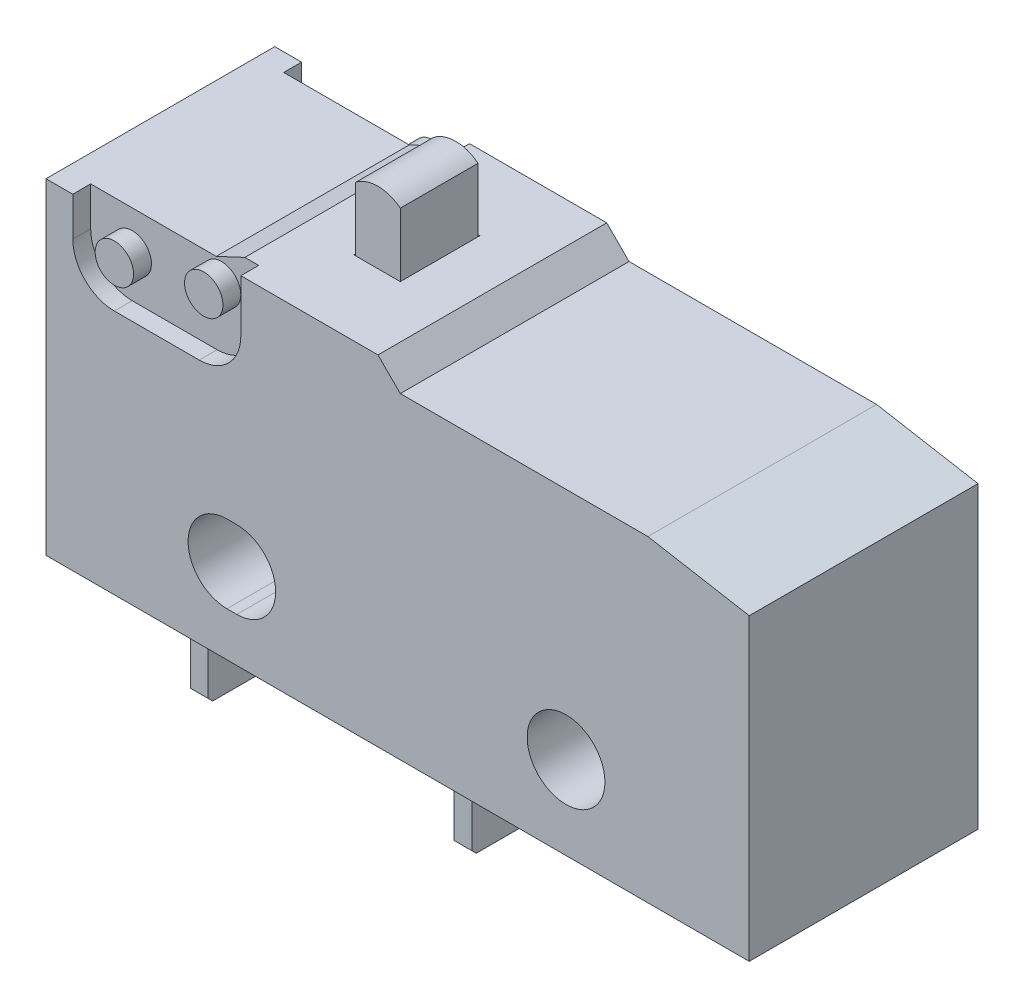
from build123d import *

# Parameters (mm, degrees)
SKETCH2_R          = 1.1049
EXTRUDE1_DEPTH     = 3.2512
EXTRUDE2_DEPTH     = 1.1049
SKETCH4_W          = 1.3208
SKETCH4_H          = 2.2606
CUT_EXTRUDE1_DEPTH = 1.016
SKETCH5_R          = 0.5461
CUT_EXTRUDE2_DEPTH = 0.508
SKETCH10_R         = 0.9017
EXTRUDE6_DEPTH     = 0.254
LPATTERN1_COUNT    = 2
LPATTERN1_PITCH    = 7.493


with BuildPart() as part:
    # Sketch2 → Extrude1 (new body, symmetric)
    with BuildSketch(Plane.XY):
        Polygon((9.9949, 8.509), (7.113888836, 9.017), (0.0762, 9.017), (-0.5588, 9.652), (-4.8514, 9.652), (-5.664596778, 9.271), (-9.9949, 9.271), (-9.9949, 0), (9.9949, 0), align=None)
        with Locations((4.7879, 2.3622)):
            Circle(SKETCH2_R, mode=Mode.SUBTRACT)
        with BuildLine():
            Line((-4.8514, 3.4671), (-4.572, 3.4671))
            ThreePointArc((-4.572, 3.4671), (-3.4671, 2.3622), (-4.572, 1.2573))
            Line((-4.572, 1.2573), (-4.8514, 1.2573))
            ThreePointArc((-4.8514, 1.2573), (-5.9563, 2.3622), (-4.8514, 3.4671))
        make_face(mode=Mode.SUBTRACT)
    extrude(amount=EXTRUDE1_DEPTH, both=True)

    # Sketch4 → Cut-Extrude1 (cut)
    with BuildSketch(Plane(origin=(0, 9.652, 0), x_dir=(-1, 0, 0), z_dir=(0, 1, 0))):
        with Locations((2.7051, 0)):
            Rectangle(SKETCH4_W, SKETCH4_H)
    extrude(amount=-CUT_EXTRUDE1_DEPTH, mode=Mode.SUBTRACT)

    # Sketch5 → Cut-Extrude2 (cut)
    with BuildSketch(Plane.XY.offset(3.2512)):
        with BuildLine():
            Line((-9.2329, 9.271), (-9.2329, 8.1661))
            ThreePointArc((-9.2329, 8.1661), (-8.886963819, 7.330936181), (-8.0518, 6.985))
            Line((-8.0518, 6.985), (-5.6388, 6.985))
            ThreePointArc((-5.6388, 6.985), (-4.803636181, 7.330936181), (-4.4577, 8.1661))
            Line((-4.4577, 8.1661), (-4.4577, 9.652))
            Line((-4.4577, 9.652), (-4.8514, 9.652))
            Line((-4.8514, 9.652), (-5.664596778, 9.271))
            Line((-5.664596778, 9.271), (-9.2329, 9.271))
        make_face()
        with Locations((-5.5118, 8.6741)):
            Circle(SKETCH5_R, mode=Mode.SUBTRACT)
        with Locations((-8.0518, 8.1661)):
            Circle(SKETCH5_R, mode=Mode.SUBTRACT)
    cut_extrude2 = extrude(amount=-CUT_EXTRUDE2_DEPTH, mode=Mode.SUBTRACT)

    # Mirror1: Cut-Extrude2 across plane
    add(cut_extrude2.mirror(Plane.XY), mode=Mode.SUBTRACT)

    # Sketch10 → Extrude6 (add, symmetric)
    with BuildSketch(Plane(origin=(-7.493, 0, 0), x_dir=(0, 0, -1), z_dir=(1, 0, 0))):
        Polygon((-1.397, 0), (-1.397, -3.0734), (-1.27, -3.2004), (1.27, -3.2004), (1.397, -3.0734), (1.397, 0), align=None)
        with Locations((0, -1.7018)):
            Circle(SKETCH10_R, mode=Mode.SUBTRACT)
    extrude6 = extrude(amount=EXTRUDE6_DEPTH, both=True)

    # LPattern1: Extrude6 ×2
    with Locations(*[(i * LPATTERN1_PITCH, 0, 0) for i in range(1, LPATTERN1_COUNT)]):
        add(extrude6)


with BuildPart() as body_2:
    # Sketch3 → Extrude2 (new body, symmetric)
    with BuildSketch(Plane.XY):
        with BuildLine():
            Line((-3.3401, 9.271), (-3.3401, 11.435714746))
            ThreePointArc((-3.3401, 11.435714746), (-2.7051, 11.6586), (-2.0701, 11.435714746))
            Line((-2.0701, 11.435714746), (-2.0701, 9.271))
            Line((-2.0701, 9.271), (-3.3401, 9.271))
        make_face()
    extrude(amount=EXTRUDE2_DEPTH, both=True)


solid = Compound([part.part, body_2.part])
